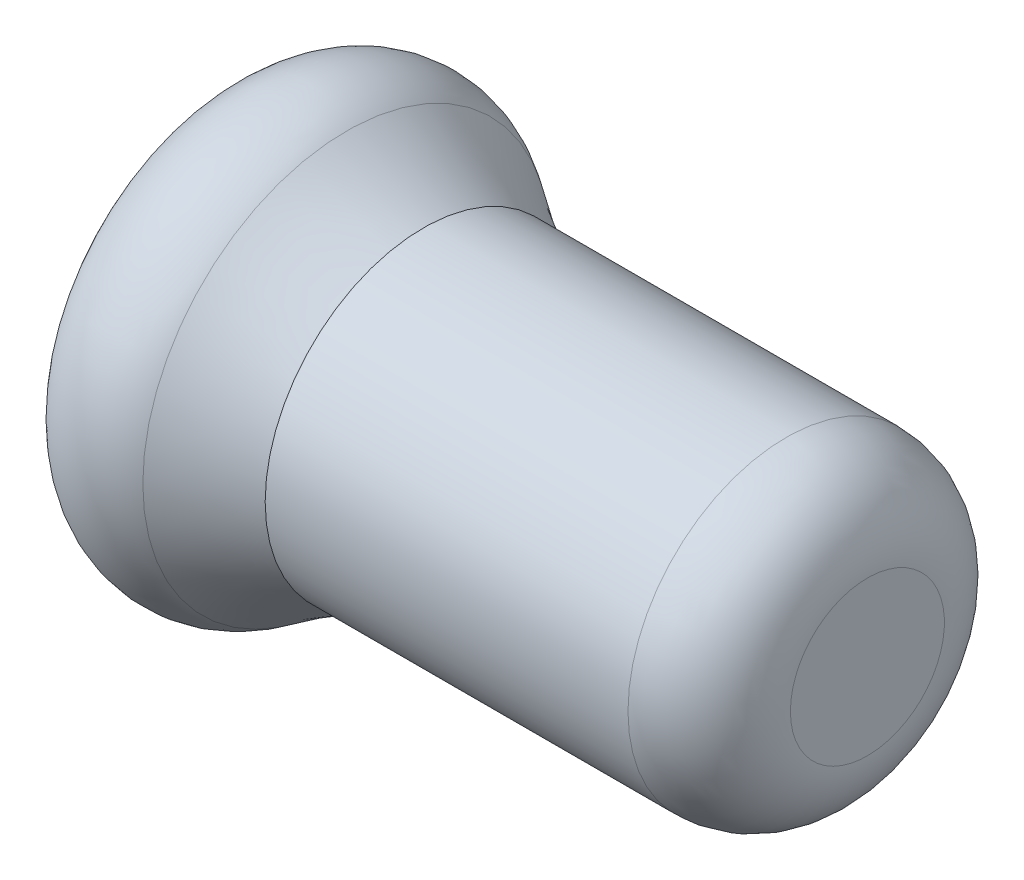
from build123d import *


with BuildPart() as part:
    # Sketch1 → Revolve1 (revolve)
    with BuildSketch(Plane.XY):
        with BuildLine():
            Line((26.680645161, 2), (26.680645161, 0))
            Line((26.680645161, 0), (21.680645161, 0))
            Line((21.680645161, 0), (21.680645161, 2.5))
            Line((21.680645161, 2.5), (-13.319354839, 2.5))
            Line((-13.319354839, 2.5), (-13.294296878, 8.9999517))
            ThreePointArc((-13.294296878, 8.9999517), (-10.365170466, 13.062306261), (-5.383476734, 12.547297834))
            ThreePointArc((-5.383476734, 12.547297834), (-3.084370729, 11.035442519), (-0.656411636, 9.740602932))
            Line((-0.656411636, 9.740602932), (21.680645161, 9.740602932))
            ThreePointArc((21.680645161, 9.740602932), (25.216179067, 8.276136838), (26.680645161, 4.740602932))
            Line((26.680645161, 4.740602932), (26.680645161, 2))
        make_face()
    revolve(axis=Axis((-16.009165471, 0, 0), (1, 0, 0)))


solid = part.part
